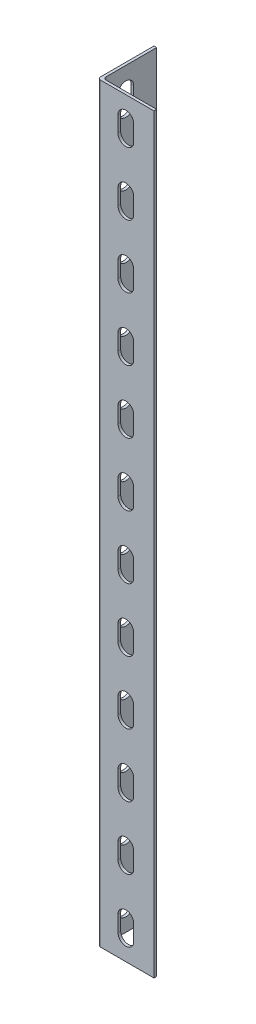
from build123d import *

# Parameters (mm, degrees)
EXTRUDE_THIN1_DEPTH       = 350
FILLET1_R                 = 1.2
CUT_EXTRUDE1_DEPTH        = 26
LPATTERN1_COUNT           = 14
LPATTERN1_PITCH           = 28
CIRPATTERN1_COUNT         = 2
CIRPATTERN1_ANGLE         = 270
CIRPATTERN1_COPY_1_DEPTH  = 26
CIRPATTERN1_COPY_2_DEPTH  = 26
CIRPATTERN1_COPY_3_DEPTH  = 26
CIRPATTERN1_COPY_4_DEPTH  = 26
CIRPATTERN1_COPY_5_DEPTH  = 26
CIRPATTERN1_COPY_6_DEPTH  = 26
CIRPATTERN1_COPY_7_DEPTH  = 26
CIRPATTERN1_COPY_8_DEPTH  = 26
CIRPATTERN1_COPY_9_DEPTH  = 26
CIRPATTERN1_COPY_10_DEPTH = 26
CIRPATTERN1_COPY_11_DEPTH = 26
CIRPATTERN1_COPY_12_DEPTH = 26
CIRPATTERN1_COPY_13_DEPTH = 26
SKETCH5_W                 = 1.2
SKETCH5_H                 = 7
SKETCH5_H_2               = 10.2
SKETCH5_W_2               = 9
SKETCH5_H_3               = 1.2
CUT_EXTRUDE3_DEPTH        = 16


with BuildPart() as part:
    # Sketch1 → Extrude-Thin1 (new body)
    with BuildSketch(Plane(origin=(0, 0, 0), x_dir=(1, 0, 0), z_dir=(0, 1, 0))):
        Polygon((25, 0), (0, 0), (0, 25), (1.2, 25), (1.2, 1.2), (25, 1.2), align=None)
    extrude(amount=EXTRUDE_THIN1_DEPTH)

    # Fillet1
    fillet1_edges = [part.edges().sort_by_distance(p)[0] for p in [
        (0, 175, 0),
        (1.2, 175, -1.2),
    ]]
    fillet(fillet1_edges, radius=FILLET1_R)

    # Sketch2 → Cut-Extrude1 (cut, through all)
    with BuildSketch(Plane.XY):
        with BuildLine():
            Line((9, 9.5), (9, 16.5))
            ThreePointArc((9, 16.5), (12.5, 20), (16, 16.5))
            Line((16, 16.5), (16, 9.5))
            ThreePointArc((16, 9.5), (12.5, 6), (9, 9.5))
        make_face()
    cut_extrude1 = extrude(amount=-CUT_EXTRUDE1_DEPTH, mode=Mode.SUBTRACT)

    # LPattern1: Cut-Extrude1 ×14
    with Locations(*[(0, i * LPATTERN1_PITCH, 0) for i in range(1, LPATTERN1_COUNT)]):
        add(cut_extrude1, mode=Mode.SUBTRACT)

    # CirPattern1: Cut-Extrude1 ×2 about axis
    cirpattern1_axis = Axis((1.2, 350, 0), (0, -1, 0))
    for i in range(1, CIRPATTERN1_COUNT):
        add(cut_extrude1.rotate(cirpattern1_axis, i * CIRPATTERN1_ANGLE / (CIRPATTERN1_COUNT - 1)), mode=Mode.SUBTRACT)

    # CirPattern1 copy 1 sketch → CirPattern1 copy 1 (cut, through all)
    with BuildSketch(Plane(origin=(1.2, 28, 1.2), x_dir=(0, 0, -1), z_dir=(1, 0, 0))):
        with BuildLine():
            Line((9, 9.5), (9, 16.5))
            ThreePointArc((9, 16.5), (12.5, 20), (16, 16.5))
            Line((16, 16.5), (16, 9.5))
            ThreePointArc((16, 9.5), (12.5, 6), (9, 9.5))
        make_face()
    extrude(amount=-CIRPATTERN1_COPY_1_DEPTH, mode=Mode.SUBTRACT)

    # CirPattern1 copy 2 sketch → CirPattern1 copy 2 (cut, through all)
    with BuildSketch(Plane(origin=(1.2, 56, 1.2), x_dir=(0, 0, -1), z_dir=(1, 0, 0))):
        with BuildLine():
            Line((9, 9.5), (9, 16.5))
            ThreePointArc((9, 16.5), (12.5, 20), (16, 16.5))
            Line((16, 16.5), (16, 9.5))
            ThreePointArc((16, 9.5), (12.5, 6), (9, 9.5))
        make_face()
    extrude(amount=-CIRPATTERN1_COPY_2_DEPTH, mode=Mode.SUBTRACT)

    # CirPattern1 copy 3 sketch → CirPattern1 copy 3 (cut, through all)
    with BuildSketch(Plane(origin=(1.2, 84, 1.2), x_dir=(0, 0, -1), z_dir=(1, 0, 0))):
        with BuildLine():
            Line((9, 9.5), (9, 16.5))
            ThreePointArc((9, 16.5), (12.5, 20), (16, 16.5))
            Line((16, 16.5), (16, 9.5))
            ThreePointArc((16, 9.5), (12.5, 6), (9, 9.5))
        make_face()
    extrude(amount=-CIRPATTERN1_COPY_3_DEPTH, mode=Mode.SUBTRACT)

    # CirPattern1 copy 4 sketch → CirPattern1 copy 4 (cut, through all)
    with BuildSketch(Plane(origin=(1.2, 112, 1.2), x_dir=(0, 0, -1), z_dir=(1, 0, 0))):
        with BuildLine():
            Line((9, 9.5), (9, 16.5))
            ThreePointArc((9, 16.5), (12.5, 20), (16, 16.5))
            Line((16, 16.5), (16, 9.5))
            ThreePointArc((16, 9.5), (12.5, 6), (9, 9.5))
        make_face()
    extrude(amount=-CIRPATTERN1_COPY_4_DEPTH, mode=Mode.SUBTRACT)

    # CirPattern1 copy 5 sketch → CirPattern1 copy 5 (cut, through all)
    with BuildSketch(Plane(origin=(1.2, 140, 1.2), x_dir=(0, 0, -1), z_dir=(1, 0, 0))):
        with BuildLine():
            Line((9, 9.5), (9, 16.5))
            ThreePointArc((9, 16.5), (12.5, 20), (16, 16.5))
            Line((16, 16.5), (16, 9.5))
            ThreePointArc((16, 9.5), (12.5, 6), (9, 9.5))
        make_face()
    extrude(amount=-CIRPATTERN1_COPY_5_DEPTH, mode=Mode.SUBTRACT)

    # CirPattern1 copy 6 sketch → CirPattern1 copy 6 (cut, through all)
    with BuildSketch(Plane(origin=(1.2, 168, 1.2), x_dir=(0, 0, -1), z_dir=(1, 0, 0))):
        with BuildLine():
            Line((9, 9.5), (9, 16.5))
            ThreePointArc((9, 16.5), (12.5, 20), (16, 16.5))
            Line((16, 16.5), (16, 9.5))
            ThreePointArc((16, 9.5), (12.5, 6), (9, 9.5))
        make_face()
    extrude(amount=-CIRPATTERN1_COPY_6_DEPTH, mode=Mode.SUBTRACT)

    # CirPattern1 copy 7 sketch → CirPattern1 copy 7 (cut, through all)
    with BuildSketch(Plane(origin=(1.2, 196, 1.2), x_dir=(0, 0, -1), z_dir=(1, 0, 0))):
        with BuildLine():
            Line((9, 9.5), (9, 16.5))
            ThreePointArc((9, 16.5), (12.5, 20), (16, 16.5))
            Line((16, 16.5), (16, 9.5))
            ThreePointArc((16, 9.5), (12.5, 6), (9, 9.5))
        make_face()
    extrude(amount=-CIRPATTERN1_COPY_7_DEPTH, mode=Mode.SUBTRACT)

    # CirPattern1 copy 8 sketch → CirPattern1 copy 8 (cut, through all)
    with BuildSketch(Plane(origin=(1.2, 224, 1.2), x_dir=(0, 0, -1), z_dir=(1, 0, 0))):
        with BuildLine():
            Line((9, 9.5), (9, 16.5))
            ThreePointArc((9, 16.5), (12.5, 20), (16, 16.5))
            Line((16, 16.5), (16, 9.5))
            ThreePointArc((16, 9.5), (12.5, 6), (9, 9.5))
        make_face()
    extrude(amount=-CIRPATTERN1_COPY_8_DEPTH, mode=Mode.SUBTRACT)

    # CirPattern1 copy 9 sketch → CirPattern1 copy 9 (cut, through all)
    with BuildSketch(Plane(origin=(1.2, 252, 1.2), x_dir=(0, 0, -1), z_dir=(1, 0, 0))):
        with BuildLine():
            Line((9, 9.5), (9, 16.5))
            ThreePointArc((9, 16.5), (12.5, 20), (16, 16.5))
            Line((16, 16.5), (16, 9.5))
            ThreePointArc((16, 9.5), (12.5, 6), (9, 9.5))
        make_face()
    extrude(amount=-CIRPATTERN1_COPY_9_DEPTH, mode=Mode.SUBTRACT)

    # CirPattern1 copy 10 sketch → CirPattern1 copy 10 (cut, through all)
    with BuildSketch(Plane(origin=(1.2, 280, 1.2), x_dir=(0, 0, -1), z_dir=(1, 0, 0))):
        with BuildLine():
            Line((9, 9.5), (9, 16.5))
            ThreePointArc((9, 16.5), (12.5, 20), (16, 16.5))
            Line((16, 16.5), (16, 9.5))
            ThreePointArc((16, 9.5), (12.5, 6), (9, 9.5))
        make_face()
    extrude(amount=-CIRPATTERN1_COPY_10_DEPTH, mode=Mode.SUBTRACT)

    # CirPattern1 copy 11 sketch → CirPattern1 copy 11 (cut, through all)
    with BuildSketch(Plane(origin=(1.2, 308, 1.2), x_dir=(0, 0, -1), z_dir=(1, 0, 0))):
        with BuildLine():
            Line((9, 9.5), (9, 16.5))
            ThreePointArc((9, 16.5), (12.5, 20), (16, 16.5))
            Line((16, 16.5), (16, 9.5))
            ThreePointArc((16, 9.5), (12.5, 6), (9, 9.5))
        make_face()
    extrude(amount=-CIRPATTERN1_COPY_11_DEPTH, mode=Mode.SUBTRACT)

    # CirPattern1 copy 12 sketch → CirPattern1 copy 12 (cut, through all)
    with BuildSketch(Plane(origin=(1.2, 336, 1.2), x_dir=(0, 0, -1), z_dir=(1, 0, 0))):
        with BuildLine():
            Line((9, 9.5), (9, 16.5))
            ThreePointArc((9, 16.5), (12.5, 20), (16, 16.5))
            Line((16, 16.5), (16, 9.5))
            ThreePointArc((16, 9.5), (12.5, 6), (9, 9.5))
        make_face()
    extrude(amount=-CIRPATTERN1_COPY_12_DEPTH, mode=Mode.SUBTRACT)

    # CirPattern1 copy 13 sketch → CirPattern1 copy 13 (cut, through all)
    with BuildSketch(Plane(origin=(1.2, 364, 1.2), x_dir=(0, 0, -1), z_dir=(1, 0, 0))):
        with BuildLine():
            Line((9, 9.5), (9, 16.5))
            ThreePointArc((9, 16.5), (12.5, 20), (16, 16.5))
            Line((16, 16.5), (16, 9.5))
            ThreePointArc((16, 9.5), (12.5, 6), (9, 9.5))
        make_face()
    extrude(amount=-CIRPATTERN1_COPY_13_DEPTH, mode=Mode.SUBTRACT)

    # Sketch5 → Cut-Extrude3 (cut)
    with BuildSketch(Plane(origin=(0, 350, 0), x_dir=(1, 0, 0), z_dir=(0, 1, 0))):
        with Locations((0.6, 11.3)):
            Rectangle(SKETCH5_W, SKETCH5_H)
        with Locations((0.6, 19.9)):
            Rectangle(SKETCH5_W, SKETCH5_H_2)
        with BuildLine():
            Line((1.2, 7.8), (0, 7.8))
            Line((0, 7.8), (0, 1.2))
            ThreePointArc((0, 1.2), (0.351471863, 0.351471863), (1.2, 0))
            Line((1.2, 0), (9, 0))
            Line((9, 0), (9, 1.2))
            Line((9, 1.2), (2.4, 1.2))
            ThreePointArc((2.4, 1.2), (1.551471863, 1.551471863), (1.2, 2.4))
            Line((1.2, 2.4), (1.2, 7.8))
        make_face()
        Polygon((9, 1.2), (9, 0), (16, 0), (16, 1.2), (10.440408388, 1.2), align=None)
        with Locations((20.5, 0.6)):
            Rectangle(SKETCH5_W_2, SKETCH5_H_3)
    extrude(amount=-CUT_EXTRUDE3_DEPTH, mode=Mode.SUBTRACT)


solid = part.part
